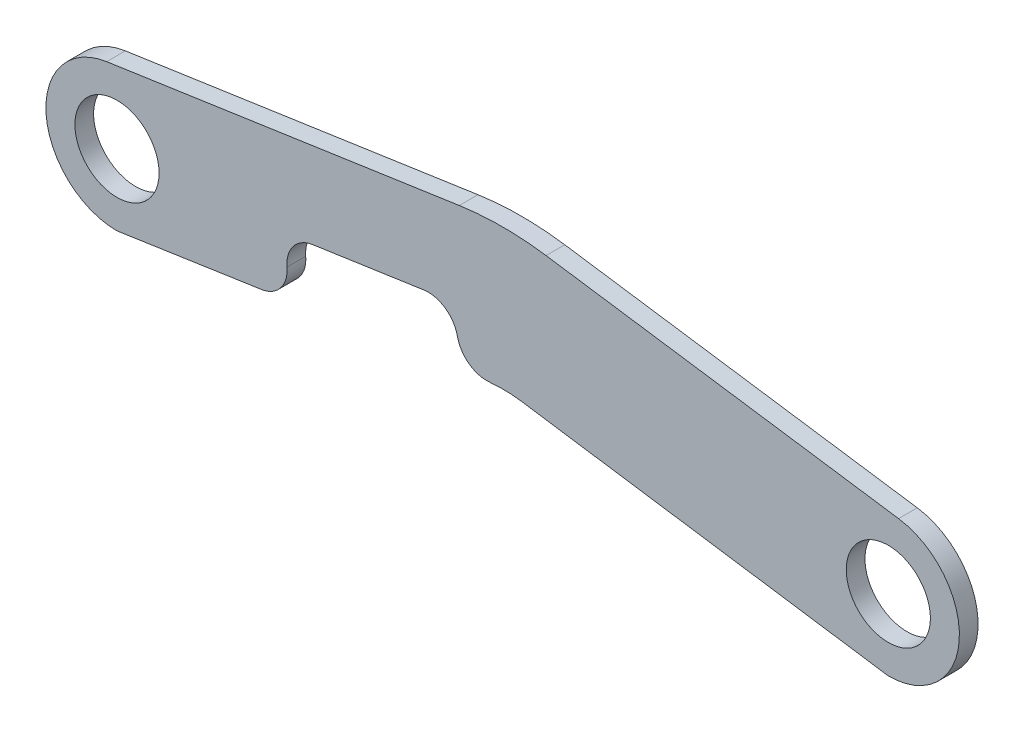
from build123d import *

# Parameters (mm, degrees)
SKETCH1_R           = 14.2875
BOSS_EXTRUDE1_DEPTH = 6.35
FILLET2_R           = 101.6
FILLET4_R           = 10.16
FILLET5_R           = 10.16
FILLET6_R           = 10.16
FILLET7_R           = 43.18
FILLET8_R           = 10.16


with BuildPart() as part:
    # Sketch1 → Boss-Extrude1 (new body)
    with BuildSketch(Plane.XY):
        with BuildLine():
            Line((-265.377394078, 23.800923648), (-130.937, 43.529137522))
            Line((-130.937, 43.529137522), (3.490632878, 23.876188601))
            ThreePointArc((3.490632878, 23.876188601), (24.066463502, -1.749924149), (0, -24.13))
            Line((0, -24.13), (-130.937, -4.730862478))
            Line((-130.937, -4.730862478), (-144.883464555, -6.804936239))
            Line((-144.883464555, -6.804936239), (-147.640874452, 11.985780223))
            Line((-147.640874452, 11.985780223), (-205.570538861, 3.484995791))
            Line((-205.570538861, 3.484995791), (-202.760210881, -15.412181497))
            Line((-202.760210881, -15.412181497), (-261.874, -24.203395818))
            ThreePointArc((-261.874, -24.203395818), (-285.939994979, -1.829751605), (-265.377394078, 23.800923648))
        make_face()
        with Locations((-261.874, -0.073395818)):
            Circle(SKETCH1_R, mode=Mode.SUBTRACT)
        Circle(SKETCH1_R, mode=Mode.SUBTRACT)
    extrude(amount=BOSS_EXTRUDE1_DEPTH)

    # Fillet2
    fillet2_edges = [part.edges().sort_by_distance(p)[0] for p in [
        (-130.937, 43.529137522, 3.175),
    ]]
    fillet(fillet2_edges, radius=FILLET2_R)

    # Fillet4
    fillet4_edges = [part.edges().sort_by_distance(p)[0] for p in [
        (-147.640874452, 11.985780223, 3.175),
    ]]
    fillet(fillet4_edges, radius=FILLET4_R)

    # Fillet5
    fillet5_edges = [part.edges().sort_by_distance(p)[0] for p in [
        (-205.570538861, 3.484995791, 3.175),
    ]]
    fillet(fillet5_edges, radius=FILLET5_R)

    # Fillet6
    fillet6_edges = [part.edges().sort_by_distance(p)[0] for p in [
        (-202.760210881, -15.412181497, 3.175),
    ]]
    fillet(fillet6_edges, radius=FILLET6_R)

    # Fillet7
    fillet7_edges = [part.edges().sort_by_distance(p)[0] for p in [
        (-130.937, -4.730862478, 3.175),
    ]]
    fillet(fillet7_edges, radius=FILLET7_R)

    # Fillet8
    fillet8_edges = [part.edges().sort_by_distance(p)[0] for p in [
        (-144.883464555, -6.804936239, 3.175),
    ]]
    fillet(fillet8_edges, radius=FILLET8_R)


solid = part.part
